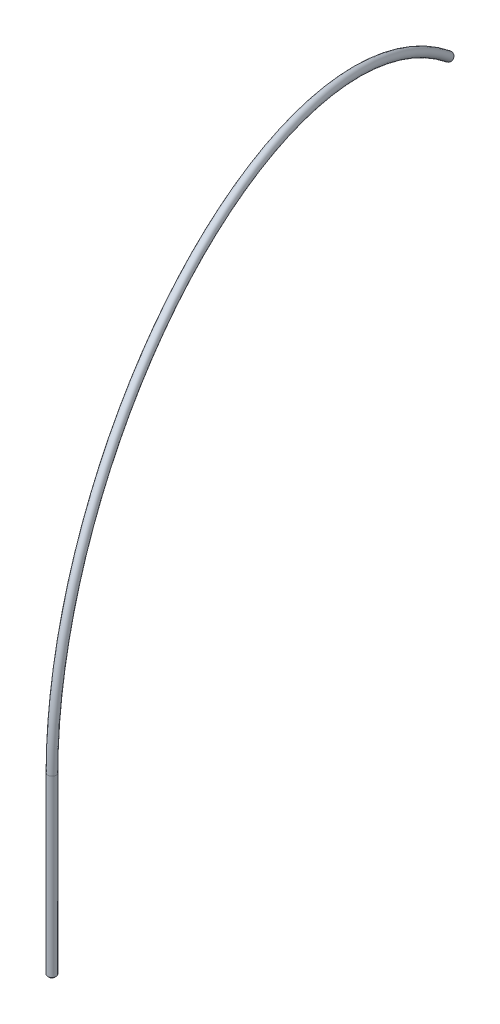
from build123d import *

# Parameters (mm, degrees)
SKETCH3_R   = 2.38125
SKETCH3_R_2 = 1.5875


with BuildPart() as part:
    # Sketch1 → Revolve1 (revolve)
    with BuildSketch(Plane.XY):
        Polygon((1.5875, 100.79375), (2.38125, 100.79375), (2.38125, 0.79375), (1.5875, 0), align=None)
    revolve(axis=Axis((0, 0, 0), (0, 1, 0)))

    # Sweep1: sweep along a path in Sketch2
    with BuildLine(Plane(origin=(0, 0, 0), x_dir=(-0.269172568, 0, -0.963091963), z_dir=(0.963091963, 0, -0.269172568))) as sweep1_path:
        ThreePointArc((0, 100.79375), (114.988872804, 281.827195122), (327.731082529, 254.6923223))
    # Sketch3 → Sweep1 (sweep)
    with BuildSketch(Plane(origin=(0, 100.79375, 0), x_dir=(1, 0, 0), z_dir=(0, 1, 0))):
        Circle(SKETCH3_R)
        Circle(SKETCH3_R_2, mode=Mode.SUBTRACT)
    sweep(path=sweep1_path.line)


solid = part.part
